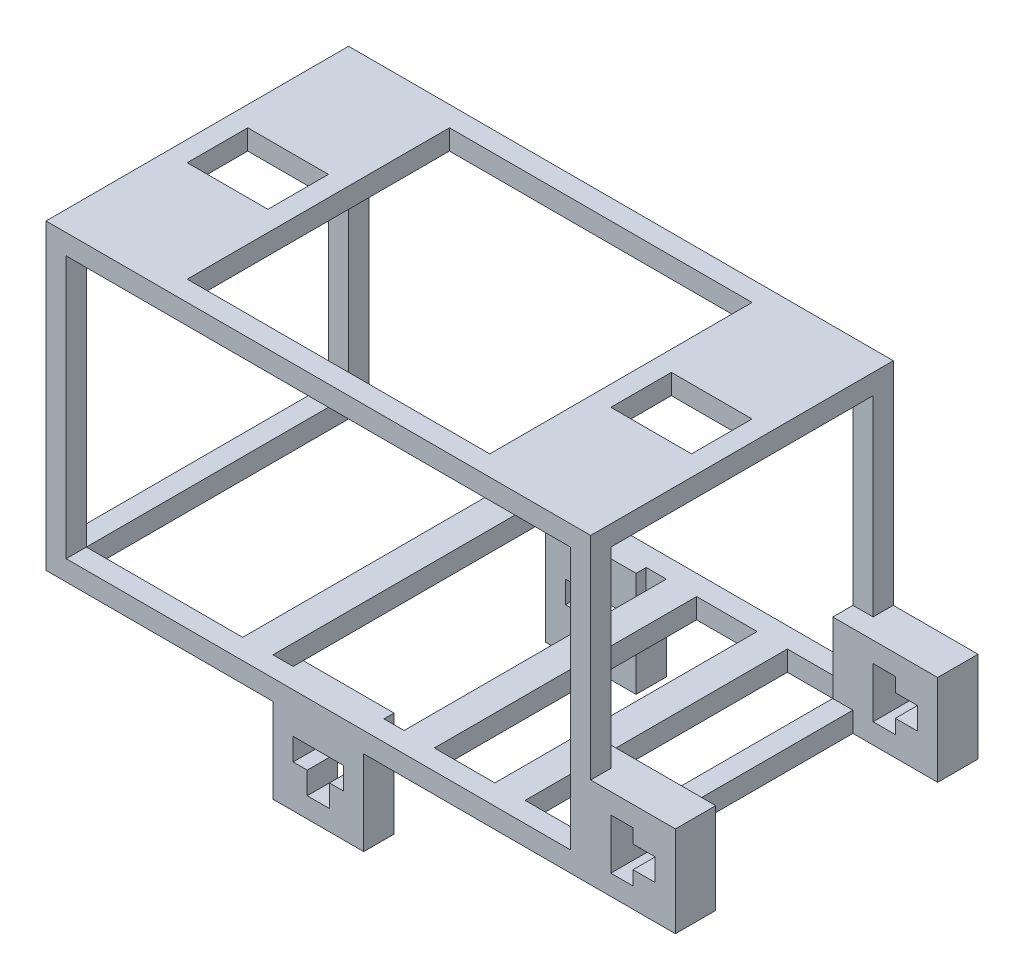
from build123d import *

# Parameters (mm, degrees)
SKETCH1_W           = 54
SKETCH1_H           = 30
SKETCH1_W_2         = 50
SKETCH1_H_2         = 26
BOSS_EXTRUDE1_DEPTH = 2
SKETCH2_W           = 2
SKETCH2_H           = 2
BOSS_EXTRUDE2_DEPTH = 28
SKETCH3_W           = 2
SKETCH3_H           = 9
BOSS_EXTRUDE3_DEPTH = 4
BOSS_EXTRUDE4_DEPTH = 3
SKETCH6_W           = 2
SKETCH6_H           = 2
BOSS_EXTRUDE5_DEPTH = 2
SKETCH10_W          = 3
SKETCH10_H          = 26
BOSS_EXTRUDE7_DEPTH = 2
SKETCH11_W          = 2
SKETCH11_H          = 6
BOSS_EXTRUDE9_DEPTH = 2


with BuildPart() as part:
    # Sketch1 → Boss-Extrude1 (new body)
    with BuildSketch(Plane(origin=(0, 0, 0), x_dir=(1, 0, 0), z_dir=(0, 1, 0))):
        Rectangle(SKETCH1_W, SKETCH1_H)
        Rectangle(SKETCH1_W_2, SKETCH1_H_2, mode=Mode.SUBTRACT)
    extrude(amount=BOSS_EXTRUDE1_DEPTH)

    # Sketch2 → Boss-Extrude2 (add)
    with BuildSketch(Plane(origin=(0, 0, 0), x_dir=(1, 0, 0), z_dir=(0, 1, 0))):
        with Locations((26, 14)):
            Rectangle(SKETCH2_W, SKETCH2_H)
        with Locations((26, -14)):
            Rectangle(SKETCH2_W, SKETCH2_H)
        with Locations((-26, -14)):
            Rectangle(SKETCH2_W, SKETCH2_H)
        with Locations((-26, 14)):
            Rectangle(SKETCH2_W, SKETCH2_H)
    extrude(amount=BOSS_EXTRUDE2_DEPTH)

    # Sketch3 → Boss-Extrude3 (add)
    with BuildSketch(Plane.XY.offset(15)):
        Polygon((27, 9), (27, 4.5), (29, 4.5), (29, 7), (31.2, 7), (31.2, 5.6), (33.4, 5.6), (33.4, 4.5), (35.4, 4.5), (35.4, 9), align=None)
        Polygon((27, 4.5), (27, 0), (35.4, 0), (35.4, 4.5), (33.4, 4.5), (33.4, 3.4), (31.2, 3.4), (31.2, 2), (29, 2), (29, 4.5), align=None)
        with Locations((26, 4.5)):
            Rectangle(SKETCH3_W, SKETCH3_H)
    boss_extrude3 = extrude(amount=-BOSS_EXTRUDE3_DEPTH)

    # Mirror1: Boss-Extrude3 across plane
    add(boss_extrude3.mirror(Plane.XY))

    # Sketch4 → Boss-Extrude4 (add)
    with BuildSketch(Plane.XY.offset(15)):
        Polygon((-4.5, 0), (0, 0), (4.5, 0), (4.5, 2), (-4.5, 2), align=None)
        Polygon((4.5, 0), (0, 0), (-4.5, 0), (-4.5, -8.4), (0, -8.4), (4.5, -8.4), align=None)
        Polygon((1.1, -6.4), (0, -6.4), (-1.1, -6.4), (-1.1, -4.2), (-2.5, -4.2), (-2.5, -2), (2.5, -2), (2.5, -4.2), (1.1, -4.2), align=None, mode=Mode.SUBTRACT)
    boss_extrude4 = extrude(amount=-BOSS_EXTRUDE4_DEPTH)

    # Mirror2: Boss-Extrude4 across plane
    add(boss_extrude4.mirror(Plane.XY))

    # Sketch6 → Boss-Extrude5 (add)
    with BuildSketch(Plane(origin=(0, 28, 0), x_dir=(1, 0, 0), z_dir=(0, 1, 0))):
        with Locations((26, -14)):
            Rectangle(SKETCH6_W, SKETCH6_H)
        Polygon((-27, -15), (25, -15), (25, -13), (27, -13), (27, 15), (-27, 15), align=None)
        Polygon((25, 6), (25, -13), (-25, -13), (-25, -9), (-25, 6), (-25, 9), (-25, 13), (25, 13), (25, 9), align=None, mode=Mode.SUBTRACT)
    extrude(amount=BOSS_EXTRUDE5_DEPTH)

    # Sketch10 → Boss-Extrude7 (add)
    with BuildSketch(Plane(origin=(0, 2, 0), x_dir=(1, 0, 0), z_dir=(0, 1, 0))):
        with Locations((8, 0)):
            Rectangle(SKETCH10_W, SKETCH10_H)
        with Locations((-8, 0)):
            Rectangle(SKETCH10_W, SKETCH10_H)
        with Locations((17, 0)):
            Rectangle(SKETCH10_W, SKETCH10_H)
    extrude(amount=-BOSS_EXTRUDE7_DEPTH)

    # Sketch11 → Boss-Extrude9 (add)
    with BuildSketch(Plane(origin=(0, 30, 0), x_dir=(1, 0, 0), z_dir=(0, 1, 0))):
        Polygon((15, -3), (15, -13), (25, -13), (25, -3), (17, -3), align=None)
        with Locations((16, 0)):
            Rectangle(SKETCH11_W, SKETCH11_H)
        Polygon((15, 13), (15, 3), (17, 3), (25, 3), (25, 13), align=None)
        Polygon((-17, 3), (-15, 3), (-15, 13), (-25, 13), (-25, 3), align=None)
        Polygon((-25, -3), (-25, -13), (-15, -13), (-15, -3), (-17, -3), align=None)
        with Locations((-16, 0)):
            Rectangle(SKETCH11_W, SKETCH11_H)
    extrude(amount=-BOSS_EXTRUDE9_DEPTH)


solid = part.part
